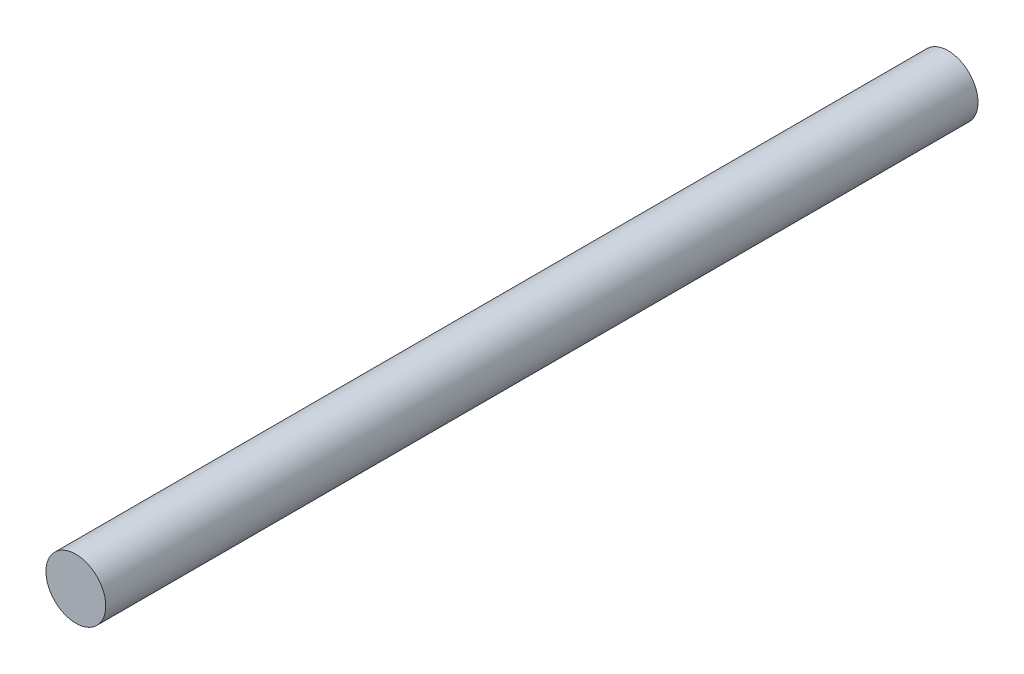
from build123d import *

# Parameters (mm, degrees)
SKETCH1_R           = 2.4
BOSS_EXTRUDE1_DEPTH = 35


with BuildPart() as part:
    # Sketch1 → Boss-Extrude1 (new body, symmetric)
    with BuildSketch(Plane.XY):
        Circle(SKETCH1_R)
    extrude(amount=BOSS_EXTRUDE1_DEPTH, both=True)


solid = part.part
